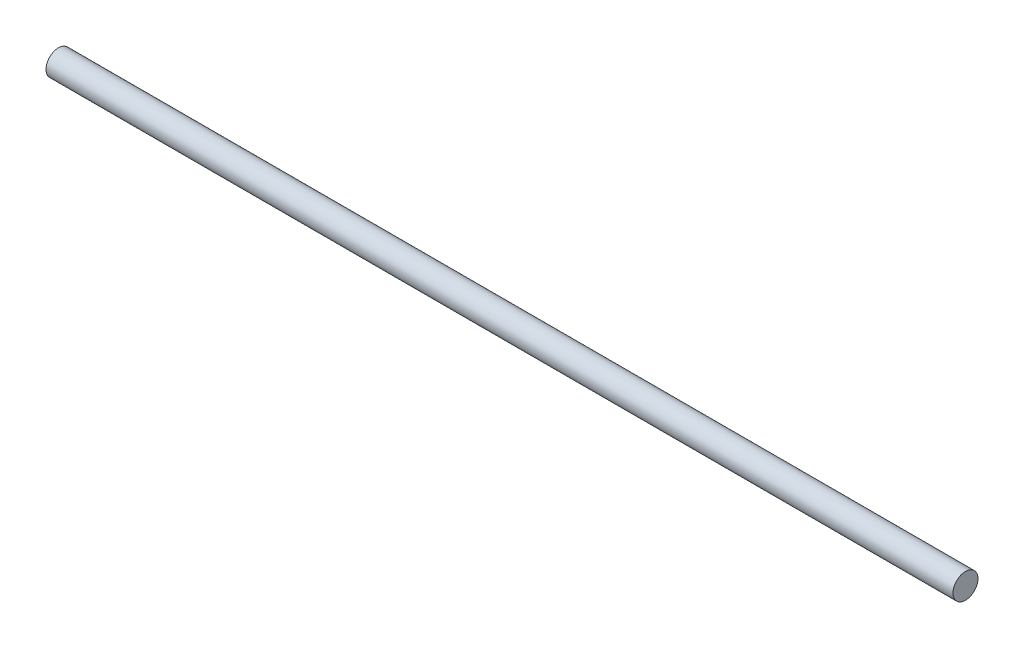
from build123d import *

# Parameters (mm, degrees)
SKETCH1_R           = 4
BOSS_EXTRUDE1_DEPTH = 290


with BuildPart() as part:
    # Sketch1 → Boss-Extrude1 (new body)
    with BuildSketch(Plane(origin=(0, 0, 0), x_dir=(0, 0, -1), z_dir=(1, 0, 0))):
        Circle(SKETCH1_R)
    extrude(amount=BOSS_EXTRUDE1_DEPTH)


solid = part.part
